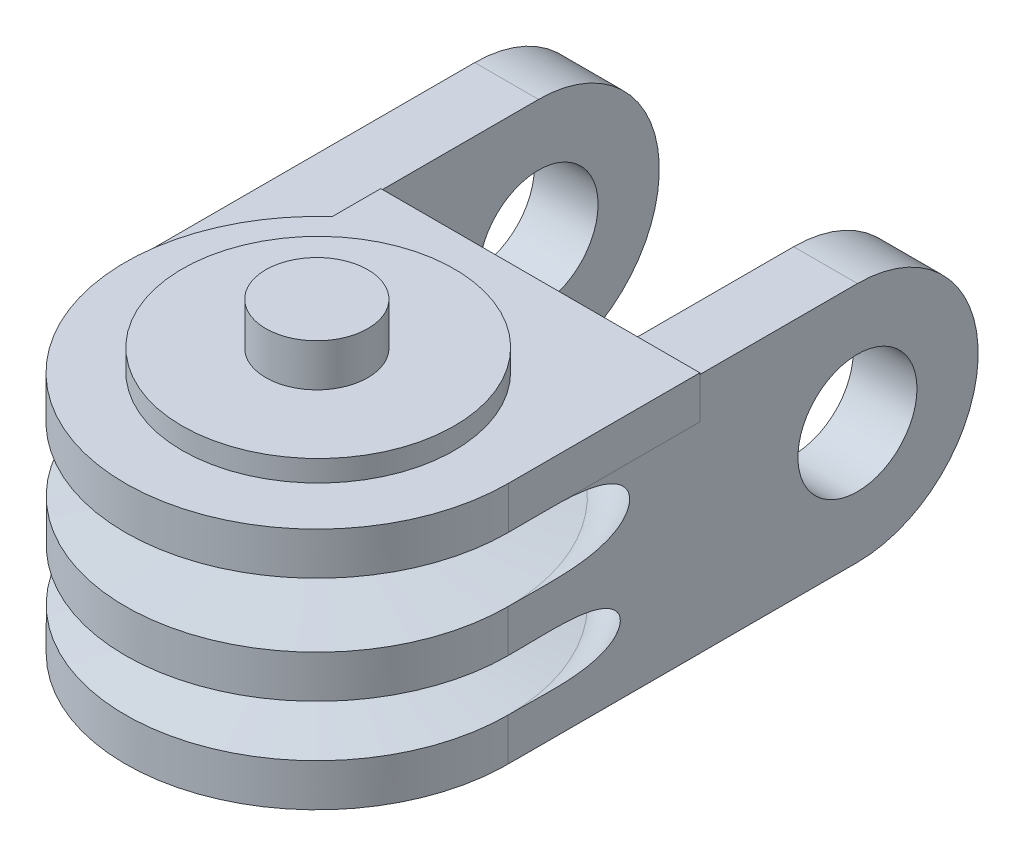
from build123d import *

# Parameters (mm, degrees)
SKETCH4_R            = 6.4
SKETCH4_R_2          = 2
BOSS_EXTRUDE3_DEPTH  = 1
BOSS_EXTRUDE6_START  = -3
SKETCH5_R            = 2.8
BOSS_EXTRUDE6_DEPTH  = 3.0001
BOSS_EXTRUDE10_DEPTH = 2
BOSS_EXTRUDE22_DEPTH = 2
SKETCH9_R            = 6.419042014
SKETCH9_R_2          = 2.4
BOSS_EXTRUDE9_DEPTH  = 1
SKETCH20_W           = 8
SKETCH20_H           = 6.154479265
SKETCH20_H_2         = 5.383738507
CUT_EXTRUDE5_DEPTH   = 18


with BuildPart() as part:
    # Sketch3 → Revolve1 (revolve)
    with BuildSketch(Plane(origin=(0, 0, 0), x_dir=(0, 0, -1), z_dir=(1, 0, 0))):
        Polygon((-0.067129815, -0.43473366), (-0.067129815, -9.299197596), (-2.467129815, -9.299197596), (-2.467129815, -1.299197596), (-9.067129815, -1.299197596), (-9.067129815, 0.700802404), (-4.067129815, 1.543966741), (-4.067129815, 2.543966741), (-9.067129815, 3.120722235), (-9.067129815, 5.120722235), (-4.067129815, 5.60045613), (-4.067129815, 7.60045613), (-9.075724319, 8.13957365), (-9.075724319, 10.13957365), (-2.467129815, 10.13957365), (-2.467129815, 18.13957365), (-0.067129815, 18.13957365), (-0.067129815, 3.856212764), align=None)
    revolve(axis=Axis((0, 3.856212764, 0.067129815), (0, -1, 0)))

    # Sketch5 → Boss-Extrude6 (add)
    with BuildSketch(Plane(origin=(-6, 0, 3.854187267), x_dir=(0, 0, -1), z_dir=(1, 0, 0)).offset(BOSS_EXTRUDE6_START)):
        with BuildLine():
            Line((20.215651957, 10.061670309), (3.787057453, 10.061670309))
            Line((3.787057453, 10.061670309), (3.787057453, -1.295637692))
            Line((3.787057453, -1.295637692), (20.215651957, -1.295637692))
            ThreePointArc((20.215651957, -1.295637692), (25.894305958, 4.383016309), (20.215651957, 10.061670309))
        make_face()
        with Locations((20.215651957, 4.383016309)):
            Circle(SKETCH5_R, mode=Mode.SUBTRACT)
    boss_extrude6 = extrude(amount=BOSS_EXTRUDE6_DEPTH)

    # Mirror1: Boss-Extrude6 across plane
    add(boss_extrude6.mirror(Plane(origin=(0, 0, 0), x_dir=(0, 0, 1), z_dir=(1, 0, 0))))

    # Sketch17 → Boss-Extrude10 (add)
    with BuildSketch(Plane(origin=(0, 10.13957365, 0), x_dir=(1, 0, 0), z_dir=(0, 1, 0))):
        with BuildLine():
            Line((9.008594505, 8.94146469), (0, 8.94146469))
            ThreePointArc((0, 8.94146469), (6.370038263, 6.302908449), (9.008594505, -0.067129815))
            Line((9.008594505, -0.067129815), (9.008594505, 8.94146469))
        make_face()
        with BuildLine():
            Line((-5.9999, 8.94146469), (-5.9999, 6.652689747))
            ThreePointArc((-5.9999, 6.652689747), (-3.2108134, 8.349844242), (0, 8.94146469))
            Line((0, 8.94146469), (-5.9999, 8.94146469))
        make_face()
    extrude(amount=-BOSS_EXTRUDE10_DEPTH)

    # Sketch18 → Boss-Extrude22 (add)
    with BuildSketch(Plane.XZ.offset(1.299197596)):
        Polygon((-6, 0.067129815), (-1.014029716, -8.201511055), (0.77631017, -8.201511055), (8.9999, -0.3285657), (8.9999, -8.94146469), (0, -8.94146469), (-6, -8.94146469), align=None)
    extrude(amount=-BOSS_EXTRUDE22_DEPTH)

    # Sketch9 → Boss-Extrude9 (add)
    with BuildSketch(Plane(origin=(0, -1.299197596, 0), x_dir=(-1, 0, 0), z_dir=(0, -1, 0))):
        with Locations(Location((0, 0, 0), (0, 0, 90))):
            Circle(SKETCH9_R)
        Circle(SKETCH9_R_2, mode=Mode.SUBTRACT)
    extrude(amount=BOSS_EXTRUDE9_DEPTH)

    # Sketch11 → Cut-Revolve3 (revolve, cut)
    with BuildSketch(Plane(origin=(0, 0, 0), x_dir=(0, 0, -1), z_dir=(1, 0, 0))):
        with BuildLine():
            ThreePointArc((-9.067129815, 5.120722235), (-10.727865544, 6.625432153), (-9.075724319, 8.13957365))
            Line((-9.075724319, 8.13957365), (-4.067129815, 7.60045613))
            Line((-4.067129815, 7.60045613), (-4.067129815, 5.60045613))
            Line((-4.067129815, 5.60045613), (-9.067129815, 5.120722235))
        make_face()
        with BuildLine():
            ThreePointArc((-9.067129815, 0.700802404), (-10.498211983, 1.91076232), (-9.067129815, 3.120722235))
            Line((-9.067129815, 3.120722235), (-4.067129815, 2.543966741))
            Line((-4.067129815, 2.543966741), (-4.067129815, 1.543966741))
            Line((-4.067129815, 1.543966741), (-9.067129815, 0.700802404))
        make_face()
    revolve(axis=Axis((0, -0.43473366, 0.067129815), (0, -1, 0)), mode=Mode.SUBTRACT)

    # Sketch20 → Cut-Extrude5 (cut)
    with BuildSketch(Plane(origin=(9, 0, 0), x_dir=(0, 0, -1), z_dir=(1, 0, 0))):
        with Locations((-0.193660705, 16.216813283)):
            Rectangle(SKETCH20_W, SKETCH20_H)
        with Locations((-0.404221955, -6.99106685)):
            Rectangle(SKETCH20_W, SKETCH20_H_2)
    extrude(amount=-CUT_EXTRUDE5_DEPTH, mode=Mode.SUBTRACT)


with BuildPart() as body_2:
    # Sketch4 → Boss-Extrude3 (new body)
    with BuildSketch(Plane(origin=(0, 10.13957365, 0), x_dir=(1, 0, 0), z_dir=(0, 1, 0))):
        with Locations(Location((0, 0, 0), (0, 0, 270))):
            Circle(SKETCH4_R)
        with Locations(Location((0, -0.067129815, 0), (0, 0, 270))):
            Circle(SKETCH4_R_2, mode=Mode.SUBTRACT)
    extrude(amount=BOSS_EXTRUDE3_DEPTH)


solid = Compound([part.part, body_2.part])
